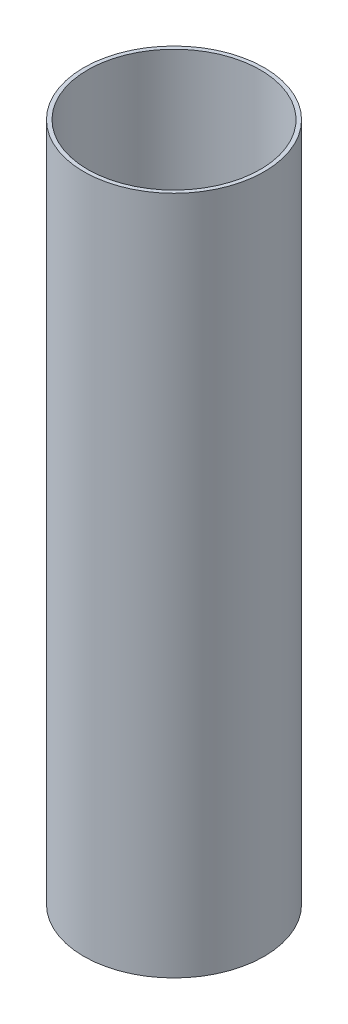
from build123d import *

# Parameters (mm, degrees)
SKETCH3_R           = 51.1048
SKETCH3_R_2         = 48.895
BOSS_EXTRUDE1_DEPTH = 385


with BuildPart() as part:
    # Sketch3 → Boss-Extrude1 (new body)
    with BuildSketch(Plane(origin=(0, 0, 0), x_dir=(1, 0, 0), z_dir=(0, 1, 0))):
        Circle(SKETCH3_R)
        Circle(SKETCH3_R_2, mode=Mode.SUBTRACT)
    extrude(amount=BOSS_EXTRUDE1_DEPTH)


solid = part.part
